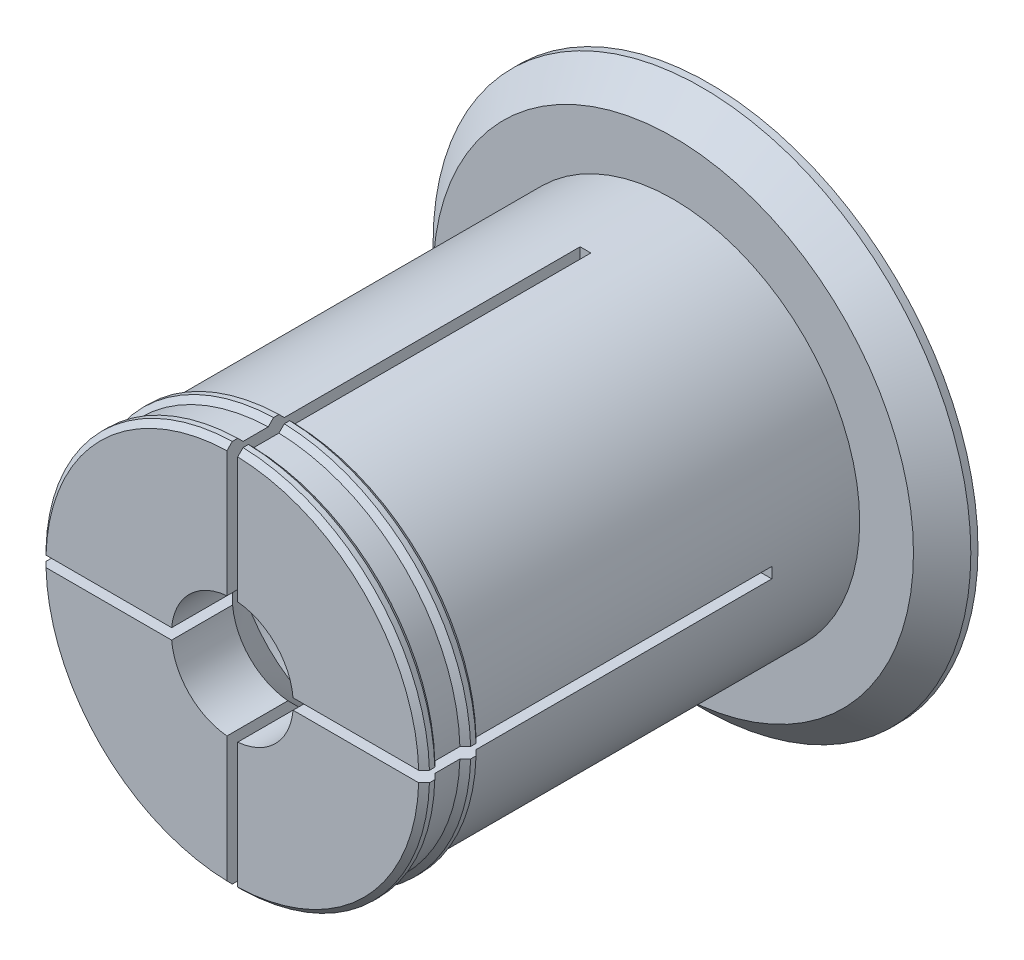
from build123d import *

# Parameters (mm, degrees)
AXLE_BASE_SKETCH_R        = 26
AXLE_DEPTH                = 61.5
GUARD_BASE_R              = 37.5
GUARD_DEPTH               = 5
INNER_AXLE_HOLE_BASE_R    = 8.5
INNER_AXLE_HOLE_DEPTH     = 67.5
BEND_START                = -49.25
BEND_ROOM_BASE_W          = 1.5
BEND_ROOM_BASE_H          = 75
BEND_ROOM_1_DEPTH         = 49.25
BEND_ROOM_2_COUNT         = 2
BEND_ROOM_2_ANGLE         = 90
EASY_REMOVAL_CHAMFER_SIZE = 4


with BuildPart() as part:
    # Axle base sketch → Axle (new body)
    with BuildSketch(Plane.XY):
        Circle(AXLE_BASE_SKETCH_R)
    extrude(amount=AXLE_DEPTH)

    # Guard base → Guard (add)
    with BuildSketch(Plane(origin=(0, 0, 0), x_dir=(-1, 0, 0), z_dir=(0, 0, -1))):
        Circle(GUARD_BASE_R)
    extrude(amount=GUARD_DEPTH)

    # Inner axle hole base → Inner axle hole (cut, through all)
    with BuildSketch(Plane.XY.offset(61.5)):
        Circle(INNER_AXLE_HOLE_BASE_R)
    extrude(amount=-INNER_AXLE_HOLE_DEPTH, mode=Mode.SUBTRACT)

    # Mate ring base → Mate rings (revolve)
    with BuildSketch(Plane(origin=(0, 0, 0), x_dir=(1, 0, 0), z_dir=(0, 1, 0))):
        Polygon((26, -61.5), (26.75, -60.75), (26.75, -60), (26, -59.25), align=None)
        Polygon((26, -55.75), (26.75, -55), (26.75, -54.25), (26, -53.5), align=None)
    revolve(axis=Axis((0, 0, 0), (0, 0, -1)))

    # Inner mass remove base → Inner mass remove (revolve, cut)
    with BuildSketch(Plane(origin=(0, 0, 0), x_dir=(0, 0, -1), z_dir=(1, 0, 0))):
        Polygon((-61.5, 0), (-44.25, -17.25), (-12.25, -17.25), (5, 0), align=None)
    revolve(axis=Axis((0, 0, 0), (0, 0, -1)), mode=Mode.SUBTRACT)

    # Bend room base → Bend room 1 (cut)
    with BuildSketch(Plane.XY.offset(61.5).offset(BEND_START)):
        Rectangle(BEND_ROOM_BASE_W, BEND_ROOM_BASE_H)
    bend_room_1 = extrude(amount=BEND_ROOM_1_DEPTH, mode=Mode.SUBTRACT)

    # Bend room 2: Bend room 1 ×2 about axis
    bend_room_2_axis = Axis((0, 0, 0), (0, 0, -1))
    for i in range(1, BEND_ROOM_2_COUNT):
        add(bend_room_1.rotate(bend_room_2_axis, i * BEND_ROOM_2_ANGLE / (BEND_ROOM_2_COUNT - 1)), mode=Mode.SUBTRACT)

    # Easy removal chamfer
    easy_removal_chamfer_edges = [part.edges().sort_by_distance(p)[0] for p in [
        (37.5, 0, 0),
    ]]
    chamfer(easy_removal_chamfer_edges, length=EASY_REMOVAL_CHAMFER_SIZE)


solid = part.part
